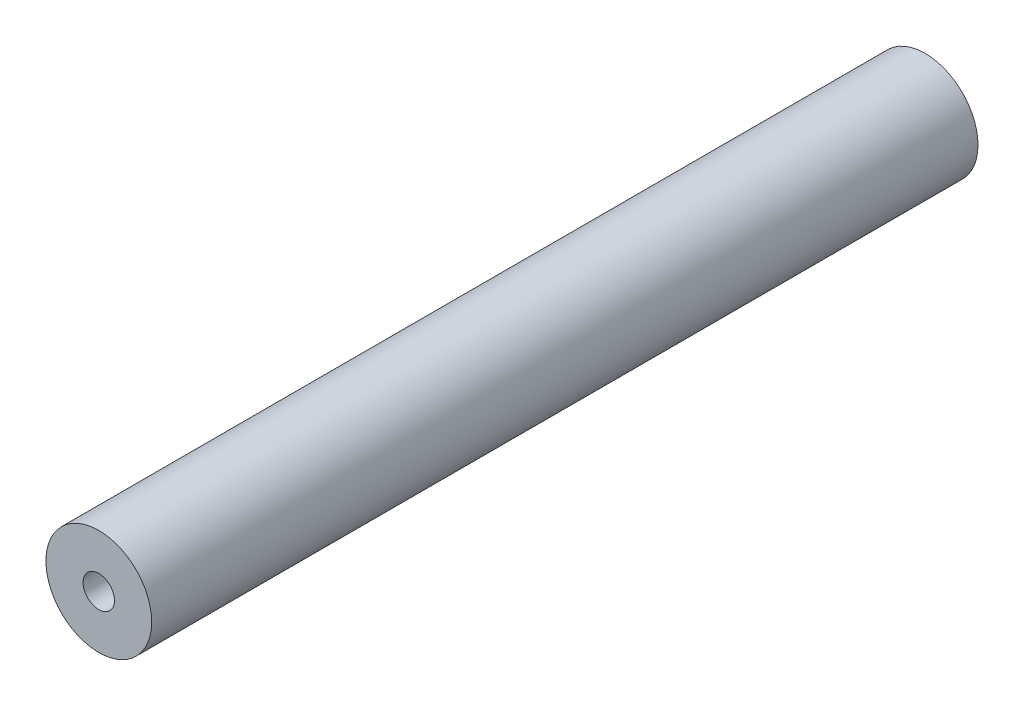
from build123d import *

# Parameters (mm, degrees)
SKETCH1_R                  = 6.4
BOSS_EXTRUDE1_DEPTH        = 100
F_10_24_TAPPED_HOLE1_D     = 3.7973
F_10_24_TAPPED_HOLE1_DEPTH = 12.83
F_10_24_TAPPED_HOLE1_TIP   = 1.140824014
F_10_24_TAPPED_HOLE2_D     = 3.7973
F_10_24_TAPPED_HOLE2_DEPTH = 12.83
F_10_24_TAPPED_HOLE2_TIP   = 1.140824014


with BuildPart() as part:
    # Sketch1 → Boss-Extrude1 (new body)
    with BuildSketch(Plane.XY):
        Circle(SKETCH1_R)
    extrude(amount=BOSS_EXTRUDE1_DEPTH)

    # #10-24 Tapped Hole1
    with Locations(Plane(origin=(0, 0, 0), x_dir=(-1, 0, 0), z_dir=(0, 0, -1))):
        with Locations((0, 0)):
            Hole(F_10_24_TAPPED_HOLE1_D / 2, depth=F_10_24_TAPPED_HOLE1_DEPTH)
            with Locations((0, 0, -(F_10_24_TAPPED_HOLE1_DEPTH + F_10_24_TAPPED_HOLE1_TIP / 2))):  # 118° drill point
                Cone(0, F_10_24_TAPPED_HOLE1_D / 2, F_10_24_TAPPED_HOLE1_TIP, mode=Mode.SUBTRACT)

    # #10-24 Tapped Hole2
    with Locations(Plane.XY.offset(100)):
        with Locations((0, 0)):
            Hole(F_10_24_TAPPED_HOLE2_D / 2, depth=F_10_24_TAPPED_HOLE2_DEPTH)
            with Locations((0, 0, -(F_10_24_TAPPED_HOLE2_DEPTH + F_10_24_TAPPED_HOLE2_TIP / 2))):  # 118° drill point
                Cone(0, F_10_24_TAPPED_HOLE2_D / 2, F_10_24_TAPPED_HOLE2_TIP, mode=Mode.SUBTRACT)


solid = part.part
